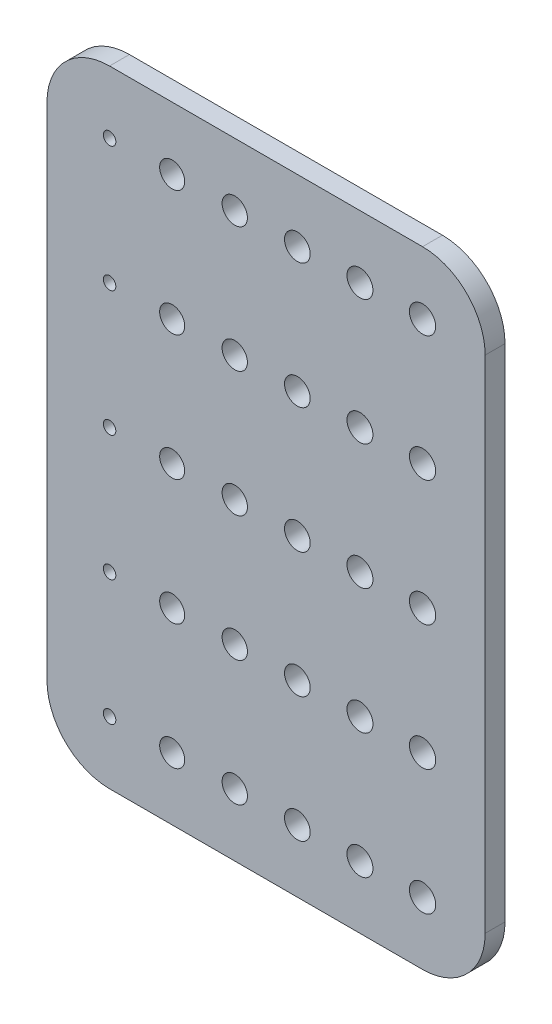
from build123d import *

# Parameters (mm, degrees)
SKETCH1_W           = 70
SKETCH1_H           = 20
SKETCH1_R           = 2
SKETCH1_R_2         = 2.025
SKETCH1_R_3         = 2.05
SKETCH1_R_4         = 2.1
SKETCH1_R_5         = 2.075
SKETCH1_R_6         = 1
BOSS_EXTRUDE1_DEPTH = 3.175
LPATTERN1_COUNT     = 5
LPATTERN1_PITCH     = 20
FILLET1_R           = 10


with BuildPart() as part:
    # Sketch1 → Boss-Extrude1 (new body)
    with BuildSketch(Plane.XY):
        with Locations((15, 0)):
            Rectangle(SKETCH1_W, SKETCH1_H)
        Circle(SKETCH1_R, mode=Mode.SUBTRACT)
        with Locations((10, 0)):
            Circle(SKETCH1_R_2, mode=Mode.SUBTRACT)
        with Locations((20, 0)):
            Circle(SKETCH1_R_3, mode=Mode.SUBTRACT)
        with Locations((40, 0)):
            Circle(SKETCH1_R_4, mode=Mode.SUBTRACT)
        with Locations((30, 0)):
            Circle(SKETCH1_R_5, mode=Mode.SUBTRACT)
        with Locations((-10, 0)):
            Circle(SKETCH1_R_6, mode=Mode.SUBTRACT)
    boss_extrude1 = extrude(amount=BOSS_EXTRUDE1_DEPTH)

    # LPattern1: Boss-Extrude1 ×5
    with Locations(*[(0, -i * LPATTERN1_PITCH, 0) for i in range(1, LPATTERN1_COUNT)]):
        add(boss_extrude1)

    # Fillet1
    fillet1_edges = [part.edges().sort_by_distance(p)[0] for p in [
        (50, -90, 1.5875),
        (-20, -90, 1.5875),
        (-20, 10, 1.5875),
        (50, 10, 1.5875),
    ]]
    fillet(fillet1_edges, radius=FILLET1_R)


solid = part.part
